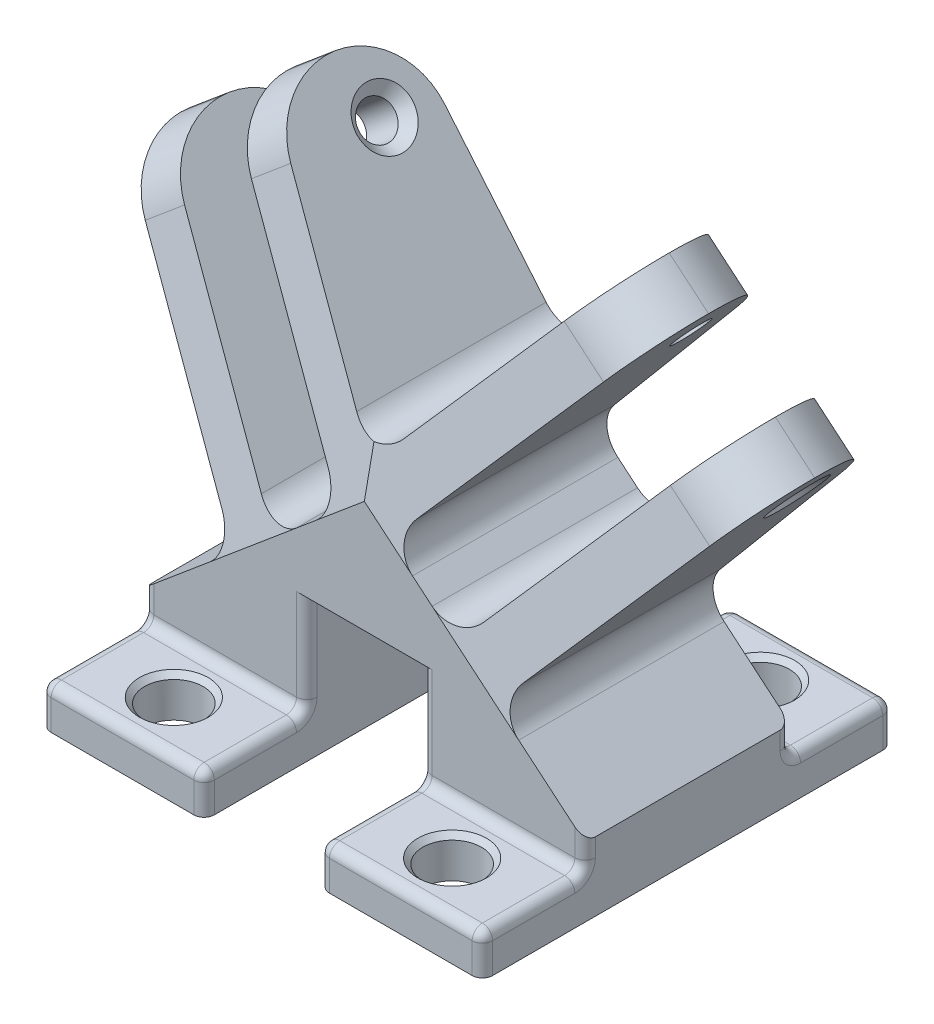
from build123d import *

# Parameters (mm, degrees)
BOSS_EXTRUDE1_DEPTH = 20
SKETCH5_R           = 1.75
CUT_EXTRUDE3_DEPTH  = 55.933306211
SKETCH6_R           = 1.75
CUT_EXTRUDE4_DEPTH  = 55.933306211
CUT_EXTRUDE5_DEPTH  = 55.933306211
CUT_EXTRUDE6_DEPTH  = 55.933306211
BOSS_EXTRUDE3_DEPTH = 10
SKETCH10_R          = 2.85
CUT_EXTRUDE7_DEPTH  = 4.933726003
BOSS_EXTRUDE4_DEPTH = 10
SKETCH12_R          = 2.85
CUT_EXTRUDE8_DEPTH  = 4.933726003
CUT_EXTRUDE9_DEPTH  = 41
CHAMFER1_SIZE       = 1
CHAMFER2_SIZE       = 0.5
FILLET1_R           = 1
FILLET2_R           = 3


with BuildPart() as part:
    # Sketch1 → Boss-Extrude1 (new body)
    with BuildSketch(Plane.XY):
        Polygon((-16.499999997, 0), (-0.605600394, 0), (-0.605600394, 13.845143912), (10.605600394, 13.845143912), (10.605600394, 0), (26.499999997, 0), (29.800788035, 3.933726003), (17.736610648, 14.0567728), (35.86606285, 35.662612593), (32.035840635, 38.876550642), (13.906388432, 17.270710848), (7.395010666, 22.73440553), (25.524462868, 44.340245324), (21.694240652, 47.554183373), (5, 27.658762099), (-11.694240652, 47.554183373), (-15.524462868, 44.340245324), (2.604989334, 22.73440553), (-3.906388432, 17.270710848), (-22.035840635, 38.876550642), (-25.86606285, 35.662612593), (-7.736610648, 14.0567728), (-19.800788035, 3.933726003), align=None)
    extrude(amount=BOSS_EXTRUDE1_DEPTH)

    # Sketch5 → Cut-Extrude3 (cut, through all)
    with BuildSketch(Plane(origin=(2.381579924, 1.998382835, 0), x_dir=(0, 0, 1), z_dir=(-0.766044443, -0.64278761, 0))):
        with Locations((5.02612125, 38.193531526)):
            Circle(SKETCH5_R)
    extrude(amount=-CUT_EXTRUDE3_DEPTH, mode=Mode.SUBTRACT)

    # Sketch6 → Cut-Extrude4 (cut, through all)
    with BuildSketch(Plane(origin=(3.486660965, -2.92565593, 0), x_dir=(0, 0, -1), z_dir=(0.766044443, -0.64278761, 0))):
        with Locations((-5.02612125, 44.621407623)):
            Circle(SKETCH6_R)
    extrude(amount=-CUT_EXTRUDE4_DEPTH, mode=Mode.SUBTRACT)

    # Sketch7 → Cut-Extrude5 (cut, through all)
    with BuildSketch(Plane(origin=(2.381579924, 1.998382835, 0), x_dir=(0, 0, 1), z_dir=(-0.766044443, -0.64278761, 0))):
        with BuildLine():
            ThreePointArc((0, 36.945530916), (2.050252532, 41.895278384), (7, 43.945530916))
            Line((7, 43.945530916), (0, 43.945530916))
            Line((0, 43.945530916), (0, 36.945530916))
        make_face()
        with BuildLine():
            ThreePointArc((7, 43.945530916), (11.317943157, 42.479786722), (13.851309254, 38.688336422))
            Line((13.851309254, 38.688336422), (20, 15.741110157))
            Line((20, 15.741110157), (20, 43.945530916))
            Line((20, 43.945530916), (7, 43.945530916))
        make_face()
    extrude(amount=-CUT_EXTRUDE5_DEPTH, mode=Mode.SUBTRACT)

    # Sketch8 → Cut-Extrude6 (cut, through all)
    with BuildSketch(Plane(origin=(3.486660965, -2.92565593, 0), x_dir=(0, 0, -1), z_dir=(0.766044443, -0.64278761, 0))):
        with BuildLine():
            Line((-20, 22.168986254), (-13.851309254, 45.116212519))
            ThreePointArc((-13.851309254, 45.116212519), (-11.317943157, 48.907662818), (-7, 50.373407013))
            Line((-7, 50.373407013), (-20, 50.373407013))
            Line((-20, 50.373407013), (-20, 22.168986254))
        make_face()
        with BuildLine():
            Line((0, 50.373407013), (-7, 50.373407013))
            ThreePointArc((-7, 50.373407013), (-2.050252532, 48.323154481), (0, 43.373407013))
            Line((0, 43.373407013), (0, 50.373407013))
        make_face()
    extrude(amount=-CUT_EXTRUDE6_DEPTH, mode=Mode.SUBTRACT)

    # Sketch9 → Boss-Extrude3 (add)
    with BuildSketch(Plane.XY.offset(20)):
        Polygon((-0.605600394, 0), (-16.499999997, 0), (-19.800788035, 3.933726003), (-0.605600394, 3.933726003), align=None)
        Polygon((10.605600394, 3.933726003), (10.605600394, 0), (26.499999997, 0), (29.800788035, 3.933726003), align=None)
    extrude(amount=BOSS_EXTRUDE3_DEPTH)

    # Sketch10 → Cut-Extrude7 (cut, through all)
    with BuildSketch(Plane(origin=(0, 3.933726003, 0), x_dir=(1, 0, 0), z_dir=(0, 1, 0))):
        with Locations((-8.552800195, -25)):
            Circle(SKETCH10_R)
        with Locations((18.552800195, -25)):
            Circle(SKETCH10_R)
    extrude(amount=-CUT_EXTRUDE7_DEPTH, mode=Mode.SUBTRACT)

    # Sketch11 → Boss-Extrude4 (add)
    with BuildSketch(Plane(origin=(0, 0, 0), x_dir=(-1, 0, 0), z_dir=(0, 0, -1))):
        Polygon((19.800788035, 3.933726003), (16.499999997, 0), (0.605600394, 0), (0.605600394, 3.933726003), align=None)
        Polygon((-10.605600394, 3.933726003), (-10.605600394, 0), (-26.499999997, 0), (-29.800788035, 3.933726003), align=None)
    extrude(amount=BOSS_EXTRUDE4_DEPTH)

    # Sketch12 → Cut-Extrude8 (cut, through all)
    with BuildSketch(Plane(origin=(0, 3.933726003, 0), x_dir=(1, 0, 0), z_dir=(0, 1, 0))):
        with Locations((-8.552800195, 5)):
            Circle(SKETCH12_R)
        with Locations((18.552800195, 5)):
            Circle(SKETCH12_R)
    extrude(amount=-CUT_EXTRUDE8_DEPTH, mode=Mode.SUBTRACT)

    # Sketch13 → Cut-Extrude9 (cut, through all)
    with BuildSketch(Plane.XY.offset(30)):
        Polygon((-16.499999997, 0), (-16.499999997, 3.933726003), (-16.499999997, 6.703416029), (-19.800788035, 3.933726003), align=None)
        Polygon((26.499999997, 0), (26.499999997, 3.933726003), (26.499999997, 6.703416029), (29.800788035, 3.933726003), align=None)
    extrude(amount=-CUT_EXTRUDE9_DEPTH, mode=Mode.SUBTRACT)

    # Chamfer1
    chamfer1_edges = [part.edges().sort_by_distance(p)[0] for p in [
        (17.996926714, 43.147896203, 6.77612125),
        (32.168748911, 31.256325424, 6.77612125),
        (-7.996926714, 43.147896203, 3.27612125),
        (-22.168748911, 31.256325424, 3.27612125),
    ]]
    chamfer(chamfer1_edges, length=CHAMFER1_SIZE)

    # Chamfer2
    chamfer2_edges = [part.edges().sort_by_distance(p)[0] for p in [
        (-11.402800195, 3.933726003, 25),
        (15.702800195, 3.933726003, 25),
        (15.702800195, 3.933726003, -5),
        (-11.402800195, 3.933726003, -5),
    ]]
    chamfer(chamfer2_edges, length=CHAMFER2_SIZE)

    # Fillet1
    fillet1_edges = [part.edges().sort_by_distance(p)[0] for p in [
        (-0.605600394, 8.889434958, 20),
        (10.605600394, 8.889434958, 20),
        (-8.552800195, 3.933726003, 20),
        (-0.605600394, 3.933726003, 25),
        (-0.605600394, 1.966863002, 30),
        (-8.552800195, 3.933726003, 30),
        (10.605600394, 3.933726003, 25),
        (10.605600394, 1.966863002, 30),
        (-0.605600394, 3.933726003, -5),
        (-0.605600394, 1.966863002, -10),
        (18.552800195, 3.933726003, 0),
        (10.605600394, 3.933726003, -5),
        (18.552800195, 3.933726003, -10),
        (10.605600394, 1.966863002, -10),
        (10.605600394, 8.889434958, 0),
        (26.499999997, 1.966863002, -10),
        (-8.552800195, 3.933726003, -10),
        (-8.552800195, 3.933726003, 0),
        (18.552800195, 3.933726003, 30),
        (18.552800195, 3.933726003, 20),
        (26.499999997, 1.966863002, 30),
        (26.499999997, 5.318571016, 20),
        (26.499999997, 5.318571016, 0),
        (26.499999997, 3.933726003, -5),
        (26.499999997, 3.933726003, 25),
        (-0.605600394, 8.889434958, 0),
        (-16.499999997, 1.966863002, 30),
        (-16.499999997, 5.318571016, 20),
        (-16.499999997, 3.933726003, 25),
        (-16.499999997, 1.966863002, -10),
        (-16.499999997, 3.933726003, -5),
        (-16.499999997, 5.318571016, 0),
    ]]
    fillet(fillet1_edges, radius=FILLET1_R)

    # Fillet2
    fillet2_edges = [part.edges().sort_by_distance(p)[0] for p in [
        (5, 27.658762099, 9.700862486),
        (-7.736610648, 14.0567728, 10),
        (-3.906388432, 17.270710848, 10),
        (2.604989334, 22.73440553, 10),
        (7.395010666, 22.73440553, 10),
        (13.906388432, 17.270710848, 10),
        (17.736610648, 14.0567728, 10),
    ]]
    fillet(fillet2_edges, radius=FILLET2_R)


solid = part.part
